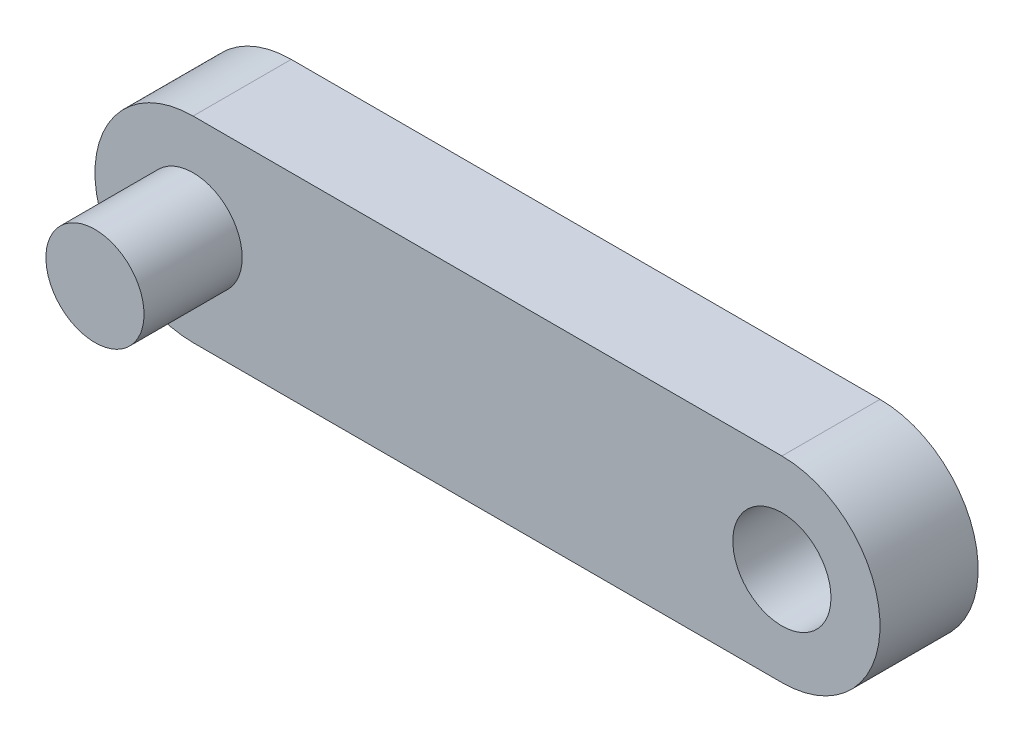
from build123d import *

# Parameters (mm, degrees)
SKETCH1_R           = 2.5
BOSS_EXTRUDE1_DEPTH = 5
SKETCH1_2_R         = 2.5
BOSS_EXTRUDE2_DEPTH = 10


with BuildPart() as part:
    # Sketch1 → Boss-Extrude1 (new body)
    with BuildSketch(Plane.XY):
        with BuildLine():
            Line((-15, 5), (15, 5))
            ThreePointArc((15, 5), (20, 0), (15, -5))
            Line((15, -5), (-15, -5))
            ThreePointArc((-15, -5), (-20, 0), (-15, 5))
        make_face()
        with Locations((-15, 0)):
            Circle(SKETCH1_R, mode=Mode.SUBTRACT)
        with Locations((15, 0)):
            Circle(SKETCH1_R, mode=Mode.SUBTRACT)
    extrude(amount=BOSS_EXTRUDE1_DEPTH)

    # Sketch1_2 → Boss-Extrude2 (add)
    with BuildSketch(Plane.XY):
        with Locations((-15, 0)):
            Circle(SKETCH1_2_R)
    extrude(amount=BOSS_EXTRUDE2_DEPTH)


solid = part.part
